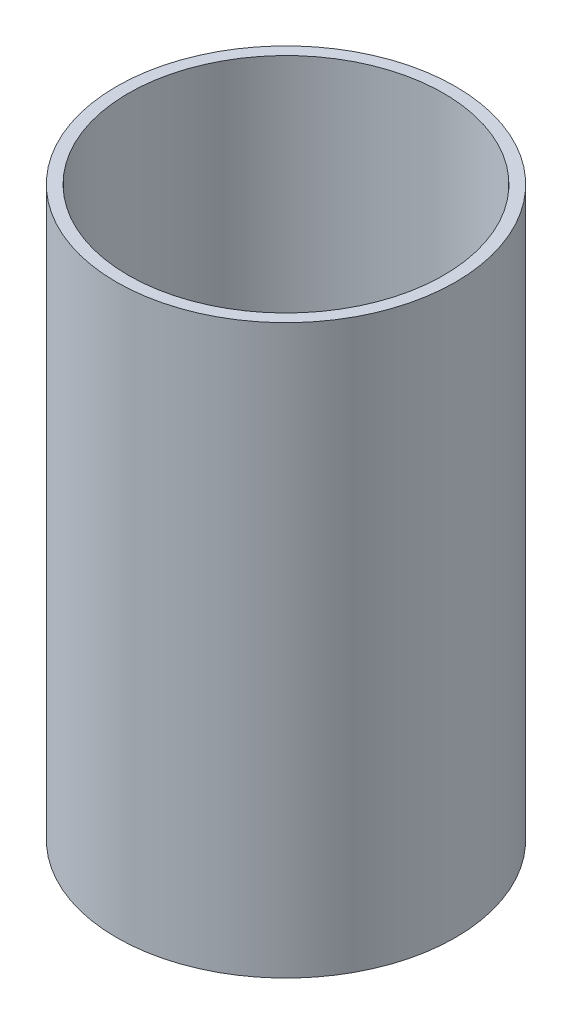
from build123d import *

# Parameters (mm, degrees)
SKETCH1_R           = 27.305
SKETCH1_R_2         = 25.4
BOSS_EXTRUDE1_DEPTH = 91.44


with BuildPart() as part:
    # Sketch1 → Boss-Extrude1 (new body)
    with BuildSketch(Plane(origin=(0, 0, 0), x_dir=(1, 0, 0), z_dir=(0, 1, 0))):
        Circle(SKETCH1_R)
        Circle(SKETCH1_R_2, mode=Mode.SUBTRACT)
    extrude(amount=BOSS_EXTRUDE1_DEPTH)


solid = part.part
